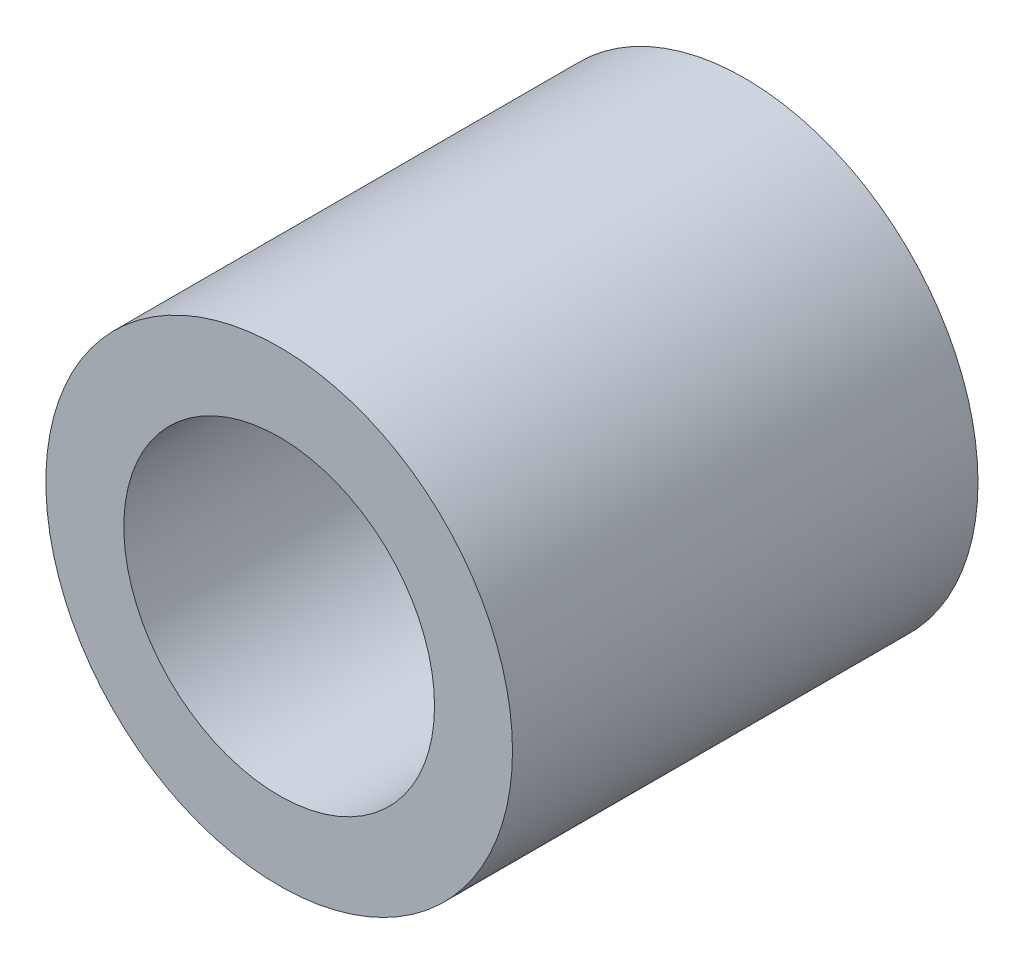
from build123d import *

# Parameters (mm, degrees)
SKETCH1_R      = 6.015
SKETCH1_R_2    = 4.005
EXTRUDE1_DEPTH = 6


with BuildPart() as part:
    # Sketch1 → Extrude1 (new body, symmetric)
    with BuildSketch(Plane.XY):
        Circle(SKETCH1_R)
        Circle(SKETCH1_R_2, mode=Mode.SUBTRACT)
    extrude(amount=EXTRUDE1_DEPTH, both=True)


solid = part.part
